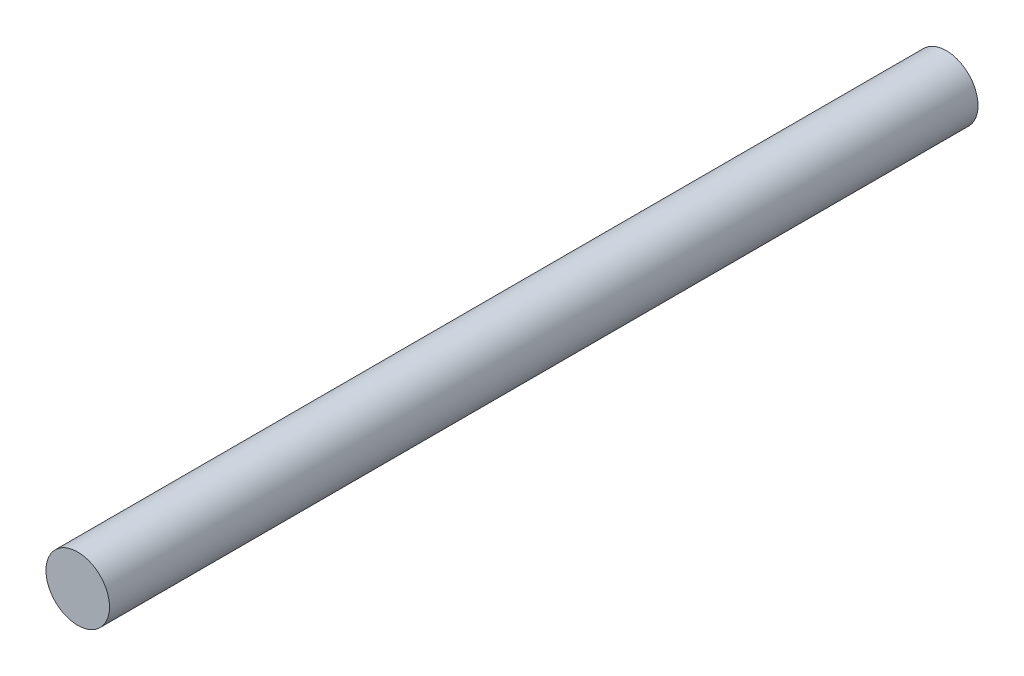
from build123d import *

# Parameters (mm, degrees)
SKETCH1_R           = 3
BOSS_EXTRUDE1_DEPTH = 82


with BuildPart() as part:
    # Sketch1 → Boss-Extrude1 (new body)
    with BuildSketch(Plane.XY):
        Circle(SKETCH1_R)
    extrude(amount=BOSS_EXTRUDE1_DEPTH)


solid = part.part
